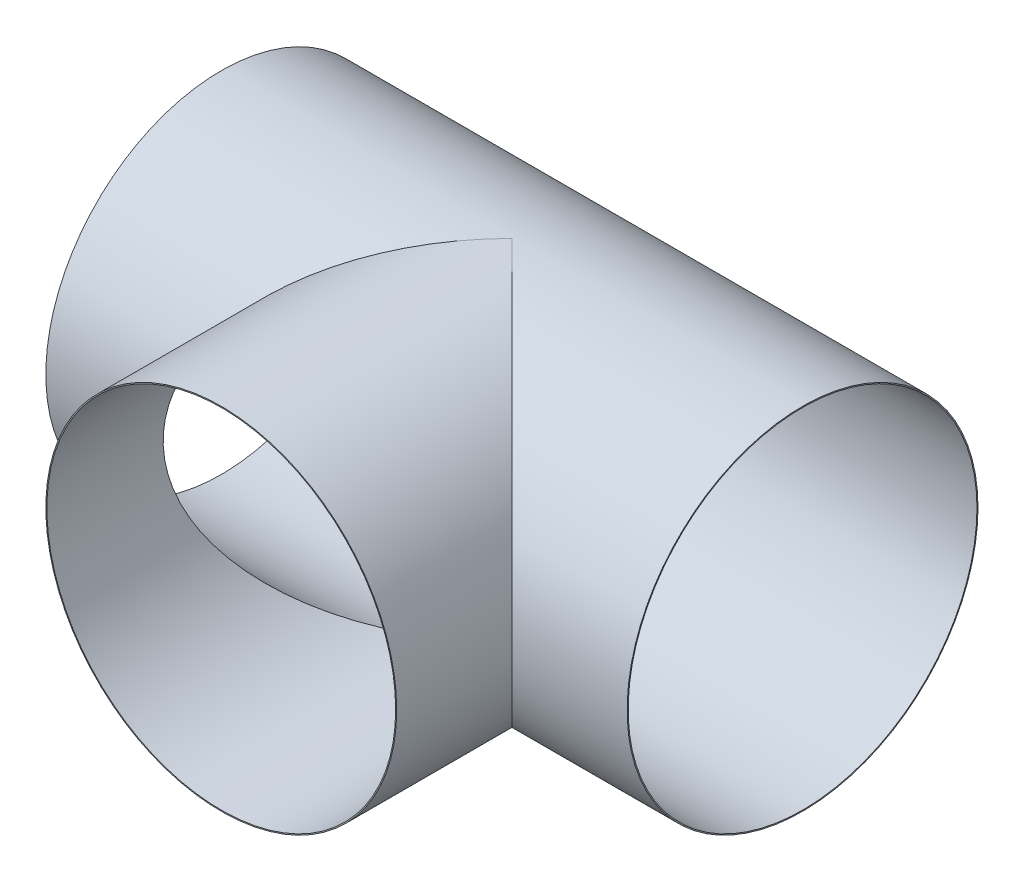
from build123d import *

# Parameters (mm, degrees)
SKETCH1_R           = 38.32733
BOSS_EXTRUDE2_DEPTH = 63.5
SKETCH2_R           = 38.32733
BOSS_EXTRUDE3_DEPTH = 127
SKETCH3_R           = 38.1
CUT_EXTRUDE1_DEPTH  = 128
SKETCH4_R           = 38.1
CUT_EXTRUDE2_DEPTH  = 63.5


with BuildPart() as part:
    # Sketch1 → Boss-Extrude2 (new body)
    with BuildSketch(Plane.XY):
        Circle(SKETCH1_R)
    extrude(amount=-BOSS_EXTRUDE2_DEPTH)

    # Sketch2 → Boss-Extrude3 (add)
    with BuildSketch(Plane(origin=(63.5, 0, 0), x_dir=(0, 0, -1), z_dir=(1, 0, 0))):
        with Locations((63.5, 0)):
            Circle(SKETCH2_R)
    extrude(amount=-BOSS_EXTRUDE3_DEPTH)

    # Sketch3 → Cut-Extrude1 (cut, through all)
    with BuildSketch(Plane(origin=(63.5, 0, 0), x_dir=(0, 0, -1), z_dir=(1, 0, 0))):
        with Locations((63.5, 0)):
            Circle(SKETCH3_R)
    extrude(amount=-CUT_EXTRUDE1_DEPTH, mode=Mode.SUBTRACT)

    # Sketch4 → Cut-Extrude2 (cut)
    with BuildSketch(Plane.XY):
        Circle(SKETCH4_R)
    extrude(amount=-CUT_EXTRUDE2_DEPTH, mode=Mode.SUBTRACT)


solid = part.part
